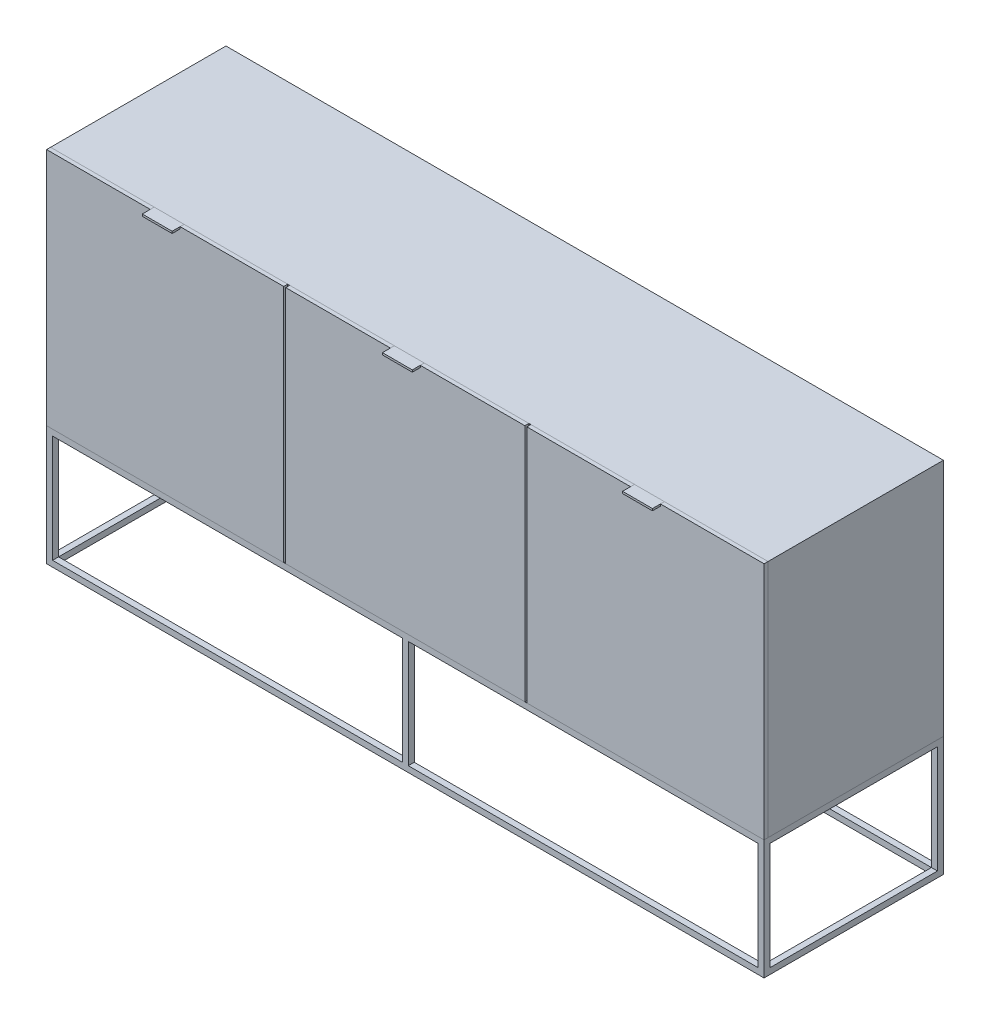
from build123d import *

# Parameters (mm, degrees)
CROQUIS1_W                = 1800
CROQUIS1_H                = 300
CROQUIS1_W_2              = 1770
CROQUIS1_H_2              = 270
SALIENTE_EXTRUIR1_DEPTH   = 450
CROQUIS2_W                = 420
CROQUIS2_H                = 270
CORTAR_EXTRUIR1_DEPTH     = 1900
CROQUIS3_W                = 1770
CROQUIS3_H                = 420
CORTAR_EXTRUIR2_DEPTH     = 400
SALIENTE_EXTRUIR2_START   = -10
CROQUIS4_W                = 1800
CROQUIS4_H                = 600
SALIENTE_EXTRUIR2_DEPTH   = 440
VACIADO1_T                = -10
CROQUIS5_W                = 595
CROQUIS5_H                = 600
SALIENTE_EXTRUIR3_DEPTH   = 10
CROQUIS5_W_2              = 600
SALIENTE_EXTRUIR3_2_DEPTH = 10
SALIENTE_EXTRUIR3_3_DEPTH = 10
CROQUIS6_W                = 15
CROQUIS6_H                = 15
SALIENTE_EXTRUIR4_DEPTH   = 300
SALIENTE_EXTRUIR5_START   = -10
CROQUIS7_W                = 10
CROQUIS7_H                = 600
SALIENTE_EXTRUIR5_DEPTH   = 430
CORTAR_EXTRUIR3_START     = 895
CROQUIS8_W                = 75
CROQUIS8_H                = 10
CORTAR_EXTRUIR3_DEPTH     = 5
SALIENTE_EXTRUIR6_START   = 900
CROQUIS9_W                = 75
CROQUIS9_H                = 30
SALIENTE_EXTRUIR6_DEPTH   = 5
SALIENTE_EXTRUIR6_2_DEPTH = 5
SALIENTE_EXTRUIR6_3_DEPTH = 5


with BuildPart() as part:
    # Croquis1 → Saliente-Extruir1 (new body)
    with BuildSketch(Plane.XY):
        with Locations((900, 150)):
            Rectangle(CROQUIS1_W, CROQUIS1_H)
        with Locations((900, 150)):
            Rectangle(CROQUIS1_W_2, CROQUIS1_H_2, mode=Mode.SUBTRACT)
    extrude(amount=-SALIENTE_EXTRUIR1_DEPTH)

    # Croquis2 → Cortar-Extruir1 (cut)
    with BuildSketch(Plane(origin=(0, 0, 0), x_dir=(0, 0, -1), z_dir=(1, 0, 0))):
        with Locations((225, 150)):
            Rectangle(CROQUIS2_W, CROQUIS2_H)
    extrude(amount=CORTAR_EXTRUIR1_DEPTH, mode=Mode.SUBTRACT)

    # Croquis3 → Cortar-Extruir2 (cut)
    with BuildSketch(Plane(origin=(0, 0, 0), x_dir=(1, 0, 0), z_dir=(0, 1, 0))):
        with Locations((900, 225)):
            Rectangle(CROQUIS3_W, CROQUIS3_H)
    extrude(amount=CORTAR_EXTRUIR2_DEPTH, mode=Mode.SUBTRACT)

    # Croquis6 → Saliente-Extruir4 (add)
    with BuildSketch(Plane(origin=(0, 0, 0), x_dir=(1, 0, 0), z_dir=(0, 1, 0))):
        with Locations((900, 7.5)):
            Rectangle(CROQUIS6_W, CROQUIS6_H)
        with Locations((900, 442.5)):
            Rectangle(CROQUIS6_W, CROQUIS6_H)
    extrude(amount=SALIENTE_EXTRUIR4_DEPTH)


with BuildPart() as body_2:
    # Croquis4 → Saliente-Extruir2 (new body)
    with BuildSketch(Plane.XY.offset(SALIENTE_EXTRUIR2_START)):
        with Locations((900, 600)):
            Rectangle(CROQUIS4_W, CROQUIS4_H)
    extrude(amount=-SALIENTE_EXTRUIR2_DEPTH)

    # Vaciado1
    vaciado1_openings = [body_2.faces().sort_by_distance(p)[0] for p in [
        (900, 600, -10),
    ]]
    offset(amount=VACIADO1_T, openings=vaciado1_openings, kind=Kind.INTERSECTION)

    # Croquis7 → Saliente-Extruir5 (add)
    with BuildSketch(Plane.XY.offset(SALIENTE_EXTRUIR5_START)):
        with Locations((597.5, 600)):
            Rectangle(CROQUIS7_W, CROQUIS7_H)
        with Locations((1202.5, 600)):
            Rectangle(CROQUIS7_W, CROQUIS7_H)
    extrude(amount=-SALIENTE_EXTRUIR5_DEPTH)


with BuildPart() as body_3:
    # Croquis5 → Saliente-Extruir3 (new body)
    with BuildSketch(Plane.XY):
        with Locations((297.5, 600)):
            Rectangle(CROQUIS5_W, CROQUIS5_H)
    extrude(amount=-SALIENTE_EXTRUIR3_DEPTH)


with BuildPart() as body_4:
    # Croquis5 → Saliente-Extruir3 2 (new body)
    with BuildSketch(Plane.XY):
        with Locations((900, 600)):
            Rectangle(CROQUIS5_W_2, CROQUIS5_H)
    extrude(amount=-SALIENTE_EXTRUIR3_2_DEPTH)


with BuildPart() as body_5:
    # Croquis5 → Saliente-Extruir3 3 (new body)
    with BuildSketch(Plane.XY):
        with Locations((1502.5, 600)):
            Rectangle(CROQUIS5_W, CROQUIS5_H)
    extrude(amount=-SALIENTE_EXTRUIR3_3_DEPTH)


with BuildPart() as cortar_extruir3_tool:
    # Croquis8 → Cortar-Extruir3 (new body)
    with BuildSketch(Plane(origin=(0, 0, 0), x_dir=(1, 0, 0), z_dir=(0, 1, 0)).offset(CORTAR_EXTRUIR3_START)):
        with Locations((297.5, 5)):
            Rectangle(CROQUIS8_W, CROQUIS8_H)
        with Locations((900, 5)):
            Rectangle(CROQUIS8_W, CROQUIS8_H)
        with Locations((1502.5, 5)):
            Rectangle(CROQUIS8_W, CROQUIS8_H)
    extrude(amount=CORTAR_EXTRUIR3_DEPTH)


with BuildPart() as body_3_1:
    add(body_3.part)

    # Cortar-Extruir3: cut by cortar_extruir3_tool
    add(cortar_extruir3_tool.part, mode=Mode.SUBTRACT)


with BuildPart() as body_4_1:
    add(body_4.part)

    # Cortar-Extruir3: cut by cortar_extruir3_tool
    add(cortar_extruir3_tool.part, mode=Mode.SUBTRACT)


with BuildPart() as body_5_1:
    add(body_5.part)

    # Cortar-Extruir3: cut by cortar_extruir3_tool
    add(cortar_extruir3_tool.part, mode=Mode.SUBTRACT)


with BuildPart() as body_6:
    # Croquis9 → Saliente-Extruir6 (new body)
    with BuildSketch(Plane(origin=(0, 0, 0), x_dir=(1, 0, 0), z_dir=(0, 1, 0)).offset(SALIENTE_EXTRUIR6_START)):
        with Locations((297.5, -5)):
            Rectangle(CROQUIS9_W, CROQUIS9_H)
    extrude(amount=-SALIENTE_EXTRUIR6_DEPTH)


with BuildPart() as body_7:
    # Croquis9 → Saliente-Extruir6 2 (new body)
    with BuildSketch(Plane(origin=(0, 0, 0), x_dir=(1, 0, 0), z_dir=(0, 1, 0)).offset(SALIENTE_EXTRUIR6_START)):
        with Locations((900, -5)):
            Rectangle(CROQUIS9_W, CROQUIS9_H)
    extrude(amount=-SALIENTE_EXTRUIR6_2_DEPTH)


with BuildPart() as body_8:
    # Croquis9 → Saliente-Extruir6 3 (new body)
    with BuildSketch(Plane(origin=(0, 0, 0), x_dir=(1, 0, 0), z_dir=(0, 1, 0)).offset(SALIENTE_EXTRUIR6_START)):
        with Locations((1502.5, -5)):
            Rectangle(CROQUIS9_W, CROQUIS9_H)
    extrude(amount=-SALIENTE_EXTRUIR6_3_DEPTH)


solid = Compound([part.part, body_2.part, body_3_1.part, body_4_1.part, body_5_1.part, body_6.part, body_7.part, body_8.part])
